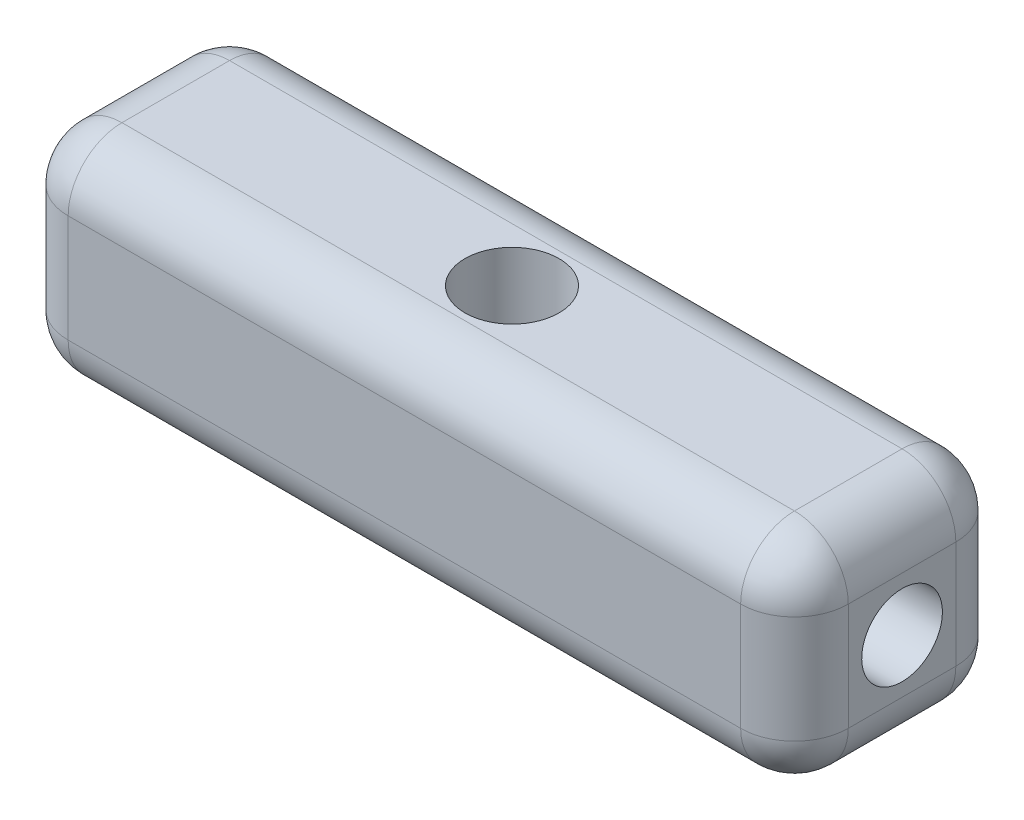
from build123d import *

# Parameters (mm, degrees)
CROQUIS1_W              = 29
CROQUIS1_H              = 8
SALIENTE_EXTRUIR1_DEPTH = 8
CROQUIS4_R              = 1.75
CORTAR_EXTRUIR1_DEPTH   = 9
REDONDEO1_R             = 2
CROQUIS5_R              = 1.5
CORTAR_EXTRUIR2_DEPTH   = 9.5
CROQUIS6_R              = 1.5
CORTAR_EXTRUIR3_DEPTH   = 9.5


with BuildPart() as part:
    # Croquis1 → Saliente-Extruir1 (new body)
    with BuildSketch(Plane.XY):
        with Locations((14.5, 4)):
            Rectangle(CROQUIS1_W, CROQUIS1_H)
    extrude(amount=SALIENTE_EXTRUIR1_DEPTH)

    # Croquis4 → Cortar-Extruir1 (cut, through all)
    with BuildSketch(Plane(origin=(0, 8, 0), x_dir=(1, 0, 0), z_dir=(0, 1, 0))):
        with Locations((14.5, -4)):
            Circle(CROQUIS4_R)
    extrude(amount=-CORTAR_EXTRUIR1_DEPTH, mode=Mode.SUBTRACT)

    # Redondeo1
    redondeo1_edges = [part.edges().sort_by_distance(p)[0] for p in [
        (29, 4, 8),
        (14.5, 8, 8),
        (0, 4, 8),
        (14.5, 8, 0),
        (29, 4, 0),
        (14.5, 0, 0),
        (0, 4, 0),
        (0, 8, 4),
        (29, 8, 4),
        (29, 0, 4),
        (0, 0, 4),
        (14.5, 0, 8),
    ]]
    fillet(redondeo1_edges, radius=REDONDEO1_R)

    # Croquis5 → Cortar-Extruir2 (cut)
    with BuildSketch(Plane(origin=(29, 0, 0), x_dir=(0, 0, -1), z_dir=(1, 0, 0))):
        with Locations((-4, 4)):
            Circle(CROQUIS5_R)
    extrude(amount=-CORTAR_EXTRUIR2_DEPTH, mode=Mode.SUBTRACT)

    # Croquis6 → Cortar-Extruir3 (cut)
    with BuildSketch(Plane.ZY):
        with Locations((4, 4)):
            Circle(CROQUIS6_R)
    extrude(amount=-CORTAR_EXTRUIR3_DEPTH, mode=Mode.SUBTRACT)


solid = part.part
